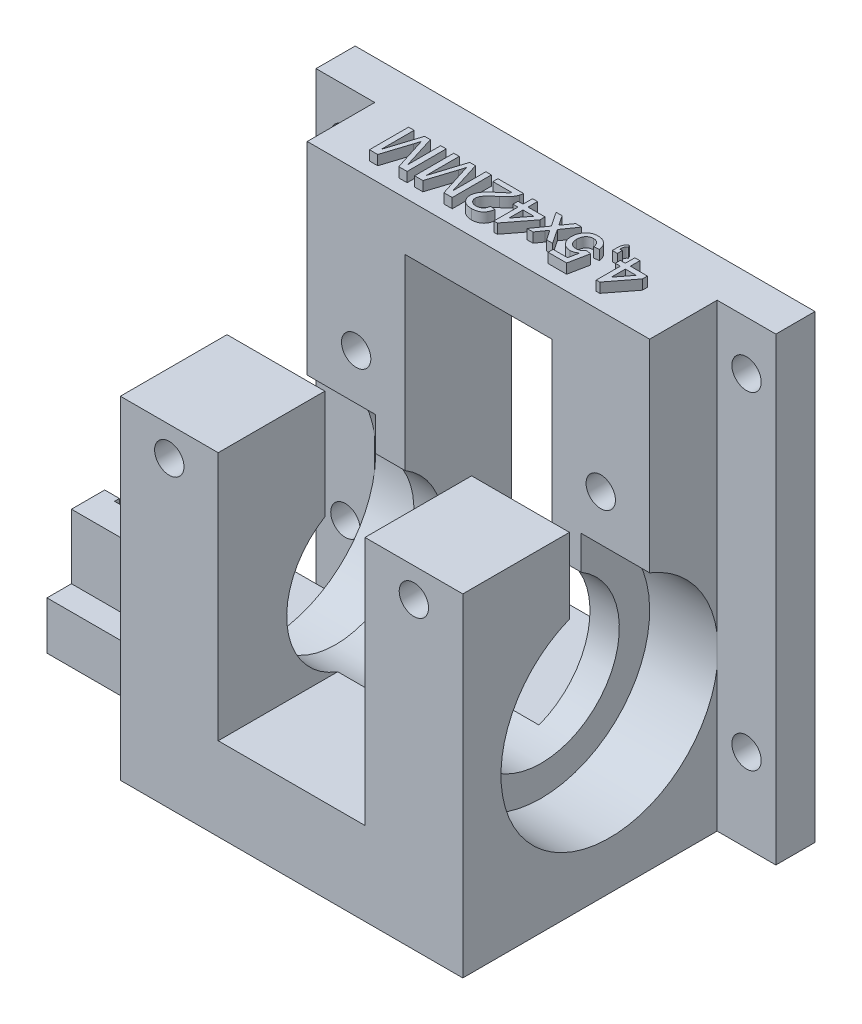
from build123d import *

# Parameters (mm, degrees)
SKETCH_1_W           = 35
SKETCH_1_H           = 30
EXTRUDE_1_DEPTH      = 42
SKETCH_2_W           = 15
SKETCH_2_H           = 30
CUT_EXTRUDE_1_DEPTH  = 33.5
SKETCH_3_R           = 11.1
CUT_EXTRUDE_2_DEPTH  = 7
SKETCH_4_R           = 11.1
CUT_EXTRUDE_3_DEPTH  = 7
SKETCH_5_R           = 8
CUT_EXTRUDE_4_DEPTH  = 29
SKETCH_6_W           = 35
SKETCH_6_H           = 8.2
CUT_EXTRUDE_5_DEPTH  = 20
SKETCH_7_R           = 1.5
CUT_EXTRUDE_6_DEPTH  = 31
SKETCH_9_W           = 15
SKETCH_9_H           = 4.9
EXTRUDE_2_DEPTH      = 15
SKETCH_10_W          = 6
SKETCH_10_H          = 10
EXTRUDE_3_DEPTH      = 6.6
CUT_EXTRUDE_8_DEPTH  = 1.3
SKETCH_12_W          = 3.2
SKETCH_12_H          = 10.2
CUT_EXTRUDE_9_DEPTH  = 1
SKETCH_14_W          = 35
SKETCH_14_H          = 10.9
EXTRUDE_4_DEPTH      = 5
SKETCH_15_W          = 10
SKETCH_15_H          = 10.9
CUT_EXTRUDE_10_DEPTH = 8
EXTRUDE_5_DEPTH      = 1
SKETCH_23_W          = 4
SKETCH_23_H          = 47
EXTRUDE_7_DEPTH      = 6
SKETCH_25_W          = 4
SKETCH_25_H          = 47
EXTRUDE_8_DEPTH      = 6
SKETCH_26_R          = 1.5
CUT_EXTRUDE_12_DEPTH = 31
SKETCH_27_R          = 3
CUT_EXTRUDE_13_DEPTH = 3


with BuildPart() as part:
    # Эскиз1 → Бобышка-Вытянуть1 (new body)
    with BuildSketch(Plane(origin=(0, 0, 0), x_dir=(1, 0, 0), z_dir=(0, 1, 0))):
        Rectangle(SKETCH_1_W, SKETCH_1_H)
    extrude(amount=EXTRUDE_1_DEPTH)

    # Эскиз2 → Вырез-Вытянуть1 (cut)
    with BuildSketch(Plane(origin=(0, 42, 0), x_dir=(1, 0, 0), z_dir=(0, 1, 0))):
        Rectangle(SKETCH_2_W, SKETCH_2_H)
    extrude(amount=-CUT_EXTRUDE_1_DEPTH, mode=Mode.SUBTRACT)

    # Эскиз3 → Вырез-Вытянуть2 (cut)
    with BuildSketch(Plane.ZY.offset(17.5)):
        with Locations((0, 16)):
            Circle(SKETCH_3_R)
    extrude(amount=-CUT_EXTRUDE_2_DEPTH, mode=Mode.SUBTRACT)

    # Эскиз4 → Вырез-Вытянуть3 (cut)
    with BuildSketch(Plane(origin=(17.5, 0, 0), x_dir=(0, 0, -1), z_dir=(1, 0, 0))):
        with Locations(Location((0, 16, 0), (0, 0, 180))):  # turned: the seam where the file's is
            Circle(SKETCH_4_R)
    extrude(amount=-CUT_EXTRUDE_3_DEPTH, mode=Mode.SUBTRACT)

    # Эскиз5 → Вырез-Вытянуть4 (cut, through all)
    with BuildSketch(Plane.ZY.offset(10.5)):
        with Locations((0, 16)):
            Circle(SKETCH_5_R)
    extrude(amount=-CUT_EXTRUDE_4_DEPTH, mode=Mode.SUBTRACT)

    # Эскиз6 → Вырез-Вытянуть5 (cut)
    with BuildSketch(Plane(origin=(0, 42, 0), x_dir=(1, 0, 0), z_dir=(0, 1, 0))):
        Rectangle(SKETCH_6_W, SKETCH_6_H)
    extrude(amount=-CUT_EXTRUDE_5_DEPTH, mode=Mode.SUBTRACT)

    # Эскиз7 → Вырез-Вытянуть6 (cut, through all)
    with BuildSketch(Plane(origin=(0, 0, -15), x_dir=(-1, 0, 0), z_dir=(0, 0, -1))):
        with Locations((-12.5, 31)):
            Circle(SKETCH_7_R)
        with Locations((12.5, 31)):
            Circle(SKETCH_7_R)
    extrude(amount=-CUT_EXTRUDE_6_DEPTH, mode=Mode.SUBTRACT)

    # Эскиз9 → Бобышка-Вытянуть2 (add)
    with BuildSketch(Plane(origin=(-17.5, 0, 0), x_dir=(0, 0, -1), z_dir=(1, 0, 0))):
        with Locations((0, 2.45)):
            Rectangle(SKETCH_9_W, SKETCH_9_H)
    extrude(amount=-EXTRUDE_2_DEPTH)

    # Эскиз10 → Бобышка-Вытянуть3 (add)
    with BuildSketch(Plane(origin=(0, 4.9, 0), x_dir=(1, 0, 0), z_dir=(0, 1, 0))):
        with Locations((-29.5, 0)):
            Rectangle(SKETCH_10_W, SKETCH_10_H)
    extrude(amount=EXTRUDE_3_DEPTH)

    # Эскиз11 → Вырез-Вытянуть8 (cut)
    with BuildSketch(Plane(origin=(0, 11.5, 0), x_dir=(1, 0, 0), z_dir=(0, 1, 0))):
        Polygon((-31, 1.6), (-32.5, 1.6), (-32.5, -1.6), (-31, -1.6), (-31, -2.1), (-28, -2.1), (-28, 2.1), (-31, 2.1), align=None)
    extrude(amount=-CUT_EXTRUDE_8_DEPTH, mode=Mode.SUBTRACT)

    # Эскиз12 → Вырез-Вытянуть9 (cut)
    with BuildSketch(Plane.ZY.offset(32.5)):
        with Locations((0, 5.1)):
            Rectangle(SKETCH_12_W, SKETCH_12_H)
    extrude(amount=-CUT_EXTRUDE_9_DEPTH, mode=Mode.SUBTRACT)

    # Эскиз14 → Бобышка-Вытянуть4 (add)
    with BuildSketch(Plane(origin=(0, 42, 0), x_dir=(1, 0, 0), z_dir=(0, 1, 0))):
        with Locations((0, 9.55)):
            Rectangle(SKETCH_14_W, SKETCH_14_H)
    extrude(amount=EXTRUDE_4_DEPTH)

    # Эскиз15 → Вырез-Вытянуть10 (cut)
    with BuildSketch(Plane(origin=(0, 42, 0), x_dir=(1, 0, 0), z_dir=(0, 1, 0))):
        with Locations((-12.5, -9.55)):
            Rectangle(SKETCH_15_W, SKETCH_15_H)
        with Locations((12.5, -9.55)):
            Rectangle(SKETCH_15_W, SKETCH_15_H)
    extrude(amount=-CUT_EXTRUDE_10_DEPTH, mode=Mode.SUBTRACT)

    # Эскиз17 → Бобышка-Вытянуть5 (add)
    with BuildSketch(Plane(origin=(0, 47, 0), x_dir=(1, 0, 0), z_dir=(0, 1, 0))):
        Polygon((11.051282051, 9.55), (11.051282051, 8.575641026), (12.794871795, 8.575641026), (12.794871795, 8.062820513), (10.897435897, 5.601282051), (10.538461538, 5.601282051), (10.538461538, 8.062820513), (10.025641026, 8.062820513), (10.025641026, 8.575641026), (10.538461538, 8.575641026), (10.538461538, 9.55), align=None)
        Polygon((11.051282051, 8.062820513), (11.051282051, 6.622115385), (12.161858974, 8.062820513), align=None, mode=Mode.SUBTRACT)
        with BuildLine():
            Line((9.256410256, 9.55), (9.256410256, 9.037179487))
            Line((9.256410256, 9.037179487), (8.743589744, 9.037179487))
            Line((8.743589744, 9.037179487), (8.743589744, 9.55))
            add(Edge.make_bspline(
                [(8.743589744, 9.55), (8.744762203, 9.60080674), (8.746998436, 9.697710464), (8.765236115, 9.835295888), (8.795282204, 9.957567435), (8.837586451, 10.066022105), (8.895741676, 10.16039483), (8.967235433, 10.243648121), (9.053922116, 10.314994822), (9.120081135, 10.351752907), (9.153846154, 10.370512821)],
                knots=[0, 0, 0, 0, 1.252840278, 2.389542986, 3.415356866, 4.352460491, 5.24846073, 6.135967884, 7.048669687, 8, 8, 8, 8], degree=3))
            Line((9.153846154, 10.370512821), (9.256410256, 10.165384615))
            add(Edge.make_bspline(
                [(9.256410256, 10.165384615), (9.236136991, 10.15270943), (9.195793548, 10.127486034), (9.144116682, 10.077328516), (9.100530598, 10.019236479), (9.065074864, 9.951439544), (9.038948006, 9.871529248), (9.019447544, 9.777755567), (9.005956084, 9.668947552), (9.003109603, 9.591175547), (9.001602564, 9.55)],
                knots=[0, 0, 0, 0, 0.818684612, 1.629167986, 2.454191951, 3.302962822, 4.242204463, 5.329983798, 6.586388792, 8, 8, 8, 8], degree=3))
            Line((9.001602564, 9.55), (9.256410256, 9.55))
        make_face()
        with BuildLine():
            Line((7.974358974, 8.473076923), (7.461538462, 8.421794872))
            add(Edge.make_bspline(
                [(7.461538462, 8.421794872), (7.456460733, 8.450689493), (7.446583762, 8.506894026), (7.427762102, 8.588251754), (7.403318124, 8.663835357), (7.375852623, 8.734299433), (7.343205242, 8.798898912), (7.307831533, 8.858653786), (7.266115474, 8.911442943), (7.222256638, 8.960027307), (7.174118215, 9.002838723), (7.121235704, 9.038930225), (7.065084563, 9.070417874), (7.004980891, 9.096198562), (6.940832572, 9.115068668), (6.873456044, 9.129991683), (6.801983712, 9.137511319), (6.753218627, 9.138989984), (6.728365385, 9.13974359)],
                knots=[0, 0, 0, 0, 1.237781394, 2.407677316, 3.51963579, 4.58689595, 5.594855907, 6.570874, 7.510833816, 8.428091223, 9.330271693, 10.221190844, 11.124215526, 12.043132878, 12.973586933, 13.941700858, 14.950982896, 16, 16, 16, 16], degree=3))
            add(Edge.make_bspline(
                [(6.728365385, 9.13974359), (6.697879298, 9.138998436), (6.638262427, 9.137541256), (6.551476168, 9.125474441), (6.469793796, 9.104984114), (6.392440011, 9.078387527), (6.320650702, 9.041973623), (6.254638587, 8.99701751), (6.192074052, 8.946020266), (6.136594245, 8.885375865), (6.086108178, 8.81931477), (6.042530672, 8.747217103), (6.005845696, 8.670082001), (5.974960646, 8.587927748), (5.952154369, 8.500284059), (5.935378488, 8.40761745), (5.924609047, 8.309868818), (5.923594873, 8.242870598), (5.923076923, 8.208653846)],
                knots=[0, 0, 0, 0, 1.052750423, 2.05869932, 3.018624241, 3.958205853, 4.878289862, 5.789216265, 6.712947111, 7.659433357, 8.620775926, 9.5811884, 10.56329027, 11.567503128, 12.60809625, 13.686605721, 14.818523251, 16, 16, 16, 16], degree=3))
            add(Edge.make_bspline(
                [(5.923076923, 8.208653846), (5.923665617, 8.176045727), (5.92481194, 8.112550156), (5.934465851, 8.020090048), (5.950753135, 7.933149565), (5.971827355, 7.850770472), (6.00087551, 7.774240043), (6.035328257, 7.702448663), (6.077534321, 7.636919954), (6.124491351, 7.575613592), (6.178122208, 7.520654908), (6.239151436, 7.47424926), (6.305184894, 7.433634947), (6.377552563, 7.400699273), (6.456297057, 7.376229304), (6.540635873, 7.357401866), (6.631444151, 7.347499404), (6.69388974, 7.3457634), (6.725961538, 7.344871795)],
                knots=[0, 0, 0, 0, 1.165854935, 2.270189951, 3.319242023, 4.32700288, 5.306253956, 6.24172124, 7.169108591, 8.088047231, 8.999810445, 9.905349262, 10.822648491, 11.767237767, 12.739852311, 13.766490849, 14.852878837, 16, 16, 16, 16], degree=3))
            add(Edge.make_bspline(
                [(6.725961538, 7.344871795), (6.765831836, 7.346075377), (6.842557476, 7.348391528), (6.952581265, 7.366774493), (7.052239813, 7.397884441), (7.141490161, 7.441871146), (7.221133837, 7.496136836), (7.292349446, 7.558219874), (7.357127652, 7.626487707), (7.39247764, 7.677959269), (7.41025641, 7.703846154)],
                knots=[0, 0, 0, 0, 1.182595606, 2.275764447, 3.298426239, 4.269611407, 5.217028086, 6.149744883, 7.069440711, 8, 8, 8, 8], degree=3))
            Line((7.41025641, 7.703846154), (7.923076923, 7.652564103))
            Line((7.923076923, 7.652564103), (7.512820513, 5.601282051))
            Line((7.512820513, 5.601282051), (5.615384615, 5.601282051))
            Line((5.615384615, 5.601282051), (5.615384615, 6.114102564))
            Line((5.615384615, 6.114102564), (7.09375, 6.114102564))
            Line((7.09375, 6.114102564), (7.297275641, 7.150160256))
            add(Edge.make_bspline(
                [(7.297275641, 7.150160256), (7.268978306, 7.128929634), (7.213406817, 7.087236051), (7.126747153, 7.032591296), (7.038983143, 6.986841178), (6.950576337, 6.948546155), (6.860301127, 6.919728313), (6.769141059, 6.899121223), (6.676964847, 6.88537448), (6.615166257, 6.884015656), (6.584134615, 6.883333333)],
                knots=[0, 0, 0, 0, 1.093799738, 2.148049664, 3.164132611, 4.152263193, 5.124065093, 6.089950765, 7.040884846, 8, 8, 8, 8], degree=3))
            add(Edge.make_bspline(
                [(6.584134615, 6.883333333), (6.543748064, 6.884391846), (6.464217151, 6.886476314), (6.347021786, 6.903592241), (6.234978069, 6.932674585), (6.127137436, 6.971751814), (6.025308421, 7.023832328), (5.927334208, 7.085605854), (5.835155558, 7.16005899), (5.748365663, 7.244413035), (5.669029336, 7.337778469), (5.600276379, 7.439053291), (5.541050547, 7.546436856), (5.493068907, 7.660316925), (5.456004725, 7.780892463), (5.429974508, 7.907543666), (5.413427229, 8.040751555), (5.411329647, 8.131680793), (5.41025641, 8.178205128)],
                knots=[0, 0, 0, 0, 0.991915953, 1.953323076, 2.9018799, 3.831962974, 4.765165785, 5.70629427, 6.67268229, 7.670376632, 8.67608782, 9.677121355, 10.672677061, 11.684236821, 12.707498642, 13.766656378, 14.857300131, 16, 16, 16, 16], degree=3))
            add(Edge.make_bspline(
                [(5.41025641, 8.178205128), (5.411156001, 8.222583072), (5.412932951, 8.310242175), (5.427752663, 8.439380631), (5.451534872, 8.564053302), (5.485561261, 8.683683722), (5.527786942, 8.799330016), (5.581285743, 8.909565964), (5.642451314, 9.016580163), (5.691606696, 9.082518807), (5.716346154, 9.115705128)],
                knots=[0, 0, 0, 0, 1.059762356, 2.093333049, 3.100576568, 4.08823236, 5.061210495, 6.037154334, 7.012117566, 8, 8, 8, 8], degree=3))
            add(Edge.make_bspline(
                [(5.716346154, 9.115705128), (5.747771179, 9.154439921), (5.809587576, 9.230635417), (5.916555204, 9.329653668), (6.031909427, 9.413416188), (6.154974873, 9.483107829), (6.287290682, 9.536524881), (6.428159547, 9.573425407), (6.577145806, 9.597839493), (6.679387351, 9.600118743), (6.731570513, 9.601282051)],
                knots=[0, 0, 0, 0, 1.023063757, 2.01247625, 2.982117532, 3.944599247, 4.908953799, 5.902627458, 6.929519989, 8, 8, 8, 8], degree=3))
            add(Edge.make_bspline(
                [(6.731570513, 9.601282051), (6.774615114, 9.600406486), (6.858818996, 9.598693703), (6.98212694, 9.583877782), (7.099337418, 9.560077146), (7.210909624, 9.526516179), (7.315783802, 9.48202305), (7.415429606, 9.429357654), (7.507610872, 9.365184154), (7.594184528, 9.293303776), (7.67336044, 9.213562045), (7.743516838, 9.126412248), (7.804411227, 9.03273972), (7.858083566, 8.933562687), (7.899810221, 8.826848145), (7.934761175, 8.714806315), (7.960674347, 8.596312118), (7.969749603, 8.514586039), (7.974358974, 8.473076923)],
                knots=[0, 0, 0, 0, 1.109091339, 2.169605288, 3.195665858, 4.188679546, 5.166738875, 6.127665597, 7.0881237, 8.055905583, 9.024592931, 9.979285586, 10.933953421, 11.900951517, 12.880148814, 13.881763063, 14.92413606, 16, 16, 16, 16], degree=3))
        make_face()
        with BuildLine():
            Line((5.102564103, 9.55), (4.076923077, 8.088461538))
            Line((4.076923077, 8.088461538), (5.051282051, 6.626923077))
            Line((5.051282051, 6.626923077), (4.436698718, 6.626923077))
            Line((4.436698718, 6.626923077), (3.963141026, 7.336057692))
            add(Edge.make_bspline(
                [(3.963141026, 7.336057692), (3.943145685, 7.366263796), (3.905403959, 7.423278603), (3.851487363, 7.503520103), (3.804239172, 7.574051249), (3.774842718, 7.617843871), (3.761217949, 7.638141026)],
                knots=[0, 0, 0, 0, 1.196329119, 2.258102392, 3.192659312, 4, 4, 4, 4], degree=3))
            add(Edge.make_bspline(
                [(3.761217949, 7.638141026), (3.728351968, 7.591408991), (3.662834044, 7.498249262), (3.597476074, 7.404977245), (3.564903846, 7.35849359)],
                knots=[0, 0, 0, 0, 1.003266858, 2, 2, 2, 2], degree=3))
            Line((3.564903846, 7.35849359), (3.051282051, 6.626923077))
            Line((3.051282051, 6.626923077), (2.4375, 6.626923077))
            Line((2.4375, 6.626923077), (3.462339744, 8.087660256))
            Line((3.462339744, 8.087660256), (2.487179487, 9.55))
            Line((2.487179487, 9.55), (3.101762821, 9.55))
            Line((3.101762821, 9.55), (3.670673077, 8.696634615))
            Line((3.670673077, 8.696634615), (3.778044872, 8.537980769))
            Line((3.778044872, 8.537980769), (4.487980769, 9.55))
            Line((4.487980769, 9.55), (5.102564103, 9.55))
        make_face()
        Polygon((0.58974359, 9.55), (0.58974359, 8.575641026), (2.333333333, 8.575641026), (2.333333333, 8.062820513), (0.435897436, 5.601282051), (0.076923077, 5.601282051), (0.076923077, 8.062820513), (-0.435897436, 8.062820513), (-0.435897436, 8.575641026), (0.076923077, 8.575641026), (0.076923077, 9.55), align=None)
        Polygon((0.58974359, 8.062820513), (0.58974359, 6.622115385), (1.700320513, 8.062820513), align=None, mode=Mode.SUBTRACT)
        with BuildLine():
            Line((-3.461538462, 9.037179487), (-3.461538462, 9.55))
            Line((-3.461538462, 9.55), (-0.846153846, 9.55))
            add(Edge.make_bspline(
                [(-0.846153846, 9.55), (-0.846082735, 9.519519453), (-0.845941371, 9.458926348), (-0.856451896, 9.368959417), (-0.872291123, 9.280102742), (-0.890639052, 9.222910301), (-0.899839744, 9.194230769)],
                knots=[0, 0, 0, 0, 1.010600758, 2.009000657, 3.001600101, 4, 4, 4, 4], degree=3))
            add(Edge.make_bspline(
                [(-0.899839744, 9.194230769), (-0.916779692, 9.147353172), (-0.951190909, 9.052127668), (-1.021694058, 8.914539873), (-1.104395846, 8.777782713), (-1.18460512, 8.665929608), (-1.25815358, 8.577261327), (-1.318832327, 8.507068152), (-1.387177214, 8.4361128), (-1.461952315, 8.36313594), (-1.542700917, 8.288131646), (-1.629420726, 8.210750893), (-1.723168438, 8.13246432), (-1.7886128, 8.080571583), (-1.822115385, 8.05400641)],
                knots=[0, 0, 0, 0, 1.204775845, 2.447339333, 3.731688634, 5.069474332, 5.771881205, 6.518320379, 7.313534551, 8.154278236, 9.045805008, 9.979490009, 10.965651065, 12, 12, 12, 12], degree=3))
            add(Edge.make_bspline(
                [(-1.822115385, 8.05400641), (-1.873583803, 8.010686271), (-1.972689508, 7.927270595), (-2.112642371, 7.803489508), (-2.240466257, 7.688551596), (-2.354126908, 7.580443046), (-2.454550075, 7.480210154), (-2.541983882, 7.388087306), (-2.617141923, 7.304339128), (-2.679226482, 7.226005854), (-2.731197355, 7.152053321), (-2.776319435, 7.080316644), (-2.812541985, 7.008283907), (-2.843626375, 6.937323066), (-2.867741932, 6.867153892), (-2.884713823, 6.797147878), (-2.895681037, 6.727967714), (-2.896857451, 6.681716305), (-2.897435897, 6.658974359)],
                knots=[0, 0, 0, 0, 1.782511555, 3.432339066, 4.950556168, 6.337242158, 7.588364383, 8.709771971, 9.70247892, 10.569050646, 11.3564271, 12.096888545, 12.812232926, 13.490631961, 14.148641375, 14.7751826, 15.397753892, 16, 16, 16, 16], degree=3))
            add(Edge.make_bspline(
                [(-2.897435897, 6.658974359), (-2.896879163, 6.636494046), (-2.89578688, 6.592388895), (-2.885421202, 6.527842176), (-2.87099607, 6.465678688), (-2.847656894, 6.40703374), (-2.819938503, 6.350109704), (-2.784024488, 6.296761456), (-2.743372767, 6.244972349), (-2.695881727, 6.197454776), (-2.64437183, 6.152921146), (-2.587038785, 6.115707339), (-2.52657792, 6.083233275), (-2.462464322, 6.05676427), (-2.39421562, 6.036629538), (-2.32231158, 6.022524983), (-2.246489973, 6.01342694), (-2.194738127, 6.012177498), (-2.168269231, 6.011538462)],
                knots=[0, 0, 0, 0, 0.987999173, 1.938400644, 2.870175051, 3.788745887, 4.708217872, 5.649938364, 6.61138593, 7.600013579, 8.600369295, 9.600725011, 10.599354487, 11.616065131, 12.645726306, 13.724038792, 14.835941382, 16, 16, 16, 16], degree=3))
            add(Edge.make_bspline(
                [(-2.168269231, 6.011538462), (-2.140465958, 6.012178615), (-2.086052911, 6.013431441), (-2.006502895, 6.022505424), (-1.931031689, 6.036484496), (-1.859837716, 6.057377903), (-1.79343005, 6.085090247), (-1.730298763, 6.116672913), (-1.672120047, 6.155686717), (-1.61882603, 6.200662994), (-1.569496464, 6.249756283), (-1.527853004, 6.305255231), (-1.491169963, 6.364389666), (-1.462860375, 6.429200021), (-1.439189909, 6.497660549), (-1.422317066, 6.570946029), (-1.413059075, 6.648857951), (-1.411204191, 6.702220684), (-1.41025641, 6.729487179)],
                knots=[0, 0, 0, 0, 1.131007971, 2.213465715, 3.25352735, 4.250693176, 5.225400803, 6.177988609, 7.118348849, 8.067272485, 9.012455277, 9.942714685, 10.883890855, 11.837222194, 12.81320114, 13.828092093, 14.890230783, 16, 16, 16, 16], degree=3))
            Line((-1.41025641, 6.729487179), (-0.897435897, 6.678205128))
            add(Edge.make_bspline(
                [(-0.897435897, 6.678205128), (-0.902682148, 6.633511111), (-0.912888276, 6.546562747), (-0.938322126, 6.420640269), (-0.973985758, 6.303468047), (-1.016806537, 6.193542674), (-1.070028073, 6.092144418), (-1.132080914, 5.998963916), (-1.201772535, 5.912932004), (-1.281651179, 5.837210809), (-1.36861221, 5.769133514), (-1.463516346, 5.710944199), (-1.565313196, 5.660697713), (-1.674316407, 5.620003899), (-1.7905577, 5.588840701), (-1.913835182, 5.566554173), (-2.044294277, 5.552801079), (-2.133779886, 5.550947015), (-2.179487179, 5.55)],
                knots=[0, 0, 0, 0, 1.130828508, 2.199929528, 3.223633236, 4.205997909, 5.160910297, 6.095620583, 7.016241394, 7.937376102, 8.855913919, 9.787436367, 10.73018861, 11.705300542, 12.706861604, 13.751074331, 14.851297925, 16, 16, 16, 16], degree=3))
            add(Edge.make_bspline(
                [(-2.179487179, 5.55), (-2.225741232, 5.550792323), (-2.315844398, 5.552335771), (-2.447141617, 5.568119175), (-2.571015121, 5.592720915), (-2.687960685, 5.626942232), (-2.797357101, 5.672137793), (-2.899578502, 5.726571863), (-2.99430275, 5.791179471), (-3.080238246, 5.865680577), (-3.157750046, 5.947040368), (-3.225520375, 6.033937345), (-3.28283039, 6.125747007), (-3.329330768, 6.222266479), (-3.366034453, 6.323411438), (-3.390931794, 6.42940932), (-3.408133355, 6.54009289), (-3.409539317, 6.615636557), (-3.41025641, 6.654166667)],
                knots=[0, 0, 0, 0, 1.195184963, 2.328227347, 3.412838735, 4.457075639, 5.472567195, 6.467212925, 7.445817268, 8.429862391, 9.40172103, 10.346392722, 11.273671097, 12.19390528, 13.111181922, 14.048965502, 15.00489906, 16, 16, 16, 16], degree=3))
            add(Edge.make_bspline(
                [(-3.41025641, 6.654166667), (-3.409177564, 6.693755674), (-3.40701749, 6.773021054), (-3.389440224, 6.89133178), (-3.361425519, 7.008540721), (-3.321690521, 7.125725416), (-3.26782673, 7.243512483), (-3.200346554, 7.364055347), (-3.116792857, 7.486526692), (-3.036708456, 7.590771671), (-2.962057858, 7.678045626), (-2.895335383, 7.750039796), (-2.819088482, 7.827693393), (-2.733561398, 7.910748414), (-2.638345813, 7.999021549), (-2.534675981, 8.093615681), (-2.42060373, 8.192635602), (-2.341395174, 8.260261046), (-2.300480769, 8.295192308)],
                knots=[0, 0, 0, 0, 0.92705835, 1.85616256, 2.795554264, 3.747284035, 4.749796966, 5.825476635, 6.979499781, 8.219726678, 8.903135141, 9.669166345, 10.518679137, 11.452302006, 12.461664484, 13.560176038, 14.739732795, 16, 16, 16, 16], degree=3))
            add(Edge.make_bspline(
                [(-2.300480769, 8.295192308), (-2.265376068, 8.323632107), (-2.198303809, 8.377970175), (-2.104154471, 8.457891049), (-2.018131649, 8.529130419), (-1.941408883, 8.592833141), (-1.874405456, 8.649747699), (-1.818010926, 8.700563375), (-1.76963496, 8.742669999), (-1.697323119, 8.808927046), (-1.605337729, 8.902681191), (-1.537302368, 8.993705132), (-1.504807692, 9.037179487)],
                knots=[0, 0, 0, 0, 1.242120814, 2.373239094, 3.395283395, 4.312960318, 5.115054069, 5.812109485, 6.400004863, 6.878180934, 8.508973911, 10, 10, 10, 10], degree=3))
            Line((-1.504807692, 9.037179487), (-3.461538462, 9.037179487))
        make_face()
        with BuildLine():
            Line((-4.128205128, 9.55), (-4.128205128, 5.55))
            Line((-4.128205128, 5.55), (-4.976762821, 5.55))
            Line((-4.976762821, 5.55), (-5.87099359, 8.356891026))
            add(Edge.make_bspline(
                [(-5.87099359, 8.356891026), (-5.880834637, 8.388688209), (-5.899866651, 8.450182111), (-5.928088868, 8.538984965), (-5.953766355, 8.621507311), (-5.976892975, 8.698011825), (-5.998717865, 8.768118663), (-6.017614781, 8.832403106), (-6.035680848, 8.890150808), (-6.04626837, 8.926851361), (-6.051282051, 8.944230769)],
                knots=[0, 0, 0, 0, 1.300204174, 2.514519184, 3.639827924, 4.676153899, 5.636536826, 6.507959918, 7.293450077, 8, 8, 8, 8], degree=3))
            add(Edge.make_bspline(
                [(-6.051282051, 8.944230769), (-6.056866128, 8.925259626), (-6.068749399, 8.88488782), (-6.088014083, 8.821410075), (-6.108512254, 8.751164808), (-6.133042282, 8.675359419), (-6.158611933, 8.592804761), (-6.185450609, 8.503569392), (-6.2164085, 8.408544221), (-6.236981565, 8.342756834), (-6.247596154, 8.308814103)],
                knots=[0, 0, 0, 0, 0.713638162, 1.518667645, 2.393860736, 3.354087503, 4.393659122, 5.512594909, 6.716633584, 8, 8, 8, 8], degree=3))
            Line((-6.247596154, 8.308814103), (-7.133012821, 5.55))
            Line((-7.133012821, 5.55), (-7.974358974, 5.55))
            Line((-7.974358974, 5.55), (-7.974358974, 9.55))
            Line((-7.974358974, 9.55), (-7.41025641, 9.55))
            Line((-7.41025641, 9.55), (-7.41025641, 6.165384615))
            Line((-7.41025641, 6.165384615), (-6.342948718, 9.55))
            Line((-6.342948718, 9.55), (-5.753205128, 9.55))
            Line((-5.753205128, 9.55), (-4.692307692, 6.165384615))
            Line((-4.692307692, 6.165384615), (-4.692307692, 9.55))
            Line((-4.692307692, 9.55), (-4.128205128, 9.55))
        make_face()
        with BuildLine():
            Line((-8.743589744, 9.55), (-8.743589744, 5.55))
            Line((-8.743589744, 5.55), (-9.592147436, 5.55))
            Line((-9.592147436, 5.55), (-10.486378205, 8.356891026))
            add(Edge.make_bspline(
                [(-10.486378205, 8.356891026), (-10.496219253, 8.388688209), (-10.515251266, 8.450182111), (-10.543473484, 8.538984965), (-10.56915097, 8.621507311), (-10.592277591, 8.698011825), (-10.614102481, 8.768118663), (-10.632999397, 8.832403106), (-10.651065463, 8.890150808), (-10.661652986, 8.926851361), (-10.666666667, 8.944230769)],
                knots=[0, 0, 0, 0, 1.300204174, 2.514519184, 3.639827924, 4.676153899, 5.636536826, 6.507959918, 7.293450077, 8, 8, 8, 8], degree=3))
            add(Edge.make_bspline(
                [(-10.666666667, 8.944230769), (-10.672250743, 8.925259626), (-10.684134015, 8.88488782), (-10.703398698, 8.821410075), (-10.723896869, 8.751164808), (-10.748426897, 8.675359419), (-10.773996548, 8.592804761), (-10.800835225, 8.503569392), (-10.831793115, 8.408544221), (-10.852366181, 8.342756834), (-10.862980769, 8.308814103)],
                knots=[0, 0, 0, 0, 0.713638162, 1.518667645, 2.393860736, 3.354087503, 4.393659122, 5.512594909, 6.716633584, 8, 8, 8, 8], degree=3))
            Line((-10.862980769, 8.308814103), (-11.748397436, 5.55))
            Line((-11.748397436, 5.55), (-12.58974359, 5.55))
            Line((-12.58974359, 5.55), (-12.58974359, 9.55))
            Line((-12.58974359, 9.55), (-12.025641026, 9.55))
            Line((-12.025641026, 9.55), (-12.025641026, 6.165384615))
            Line((-12.025641026, 6.165384615), (-10.958333333, 9.55))
            Line((-10.958333333, 9.55), (-10.368589744, 9.55))
            Line((-10.368589744, 9.55), (-9.307692308, 6.165384615))
            Line((-9.307692308, 6.165384615), (-9.307692308, 9.55))
            Line((-9.307692308, 9.55), (-8.743589744, 9.55))
        make_face()
    extrude(amount=EXTRUDE_5_DEPTH)

    # Эскиз23 → Бобышка-Вытянуть7 (add)
    with BuildSketch(Plane(origin=(17.5, 0, 0), x_dir=(0, 0, -1), z_dir=(1, 0, 0))):
        with Locations((13, 23.5)):
            Rectangle(SKETCH_23_W, SKETCH_23_H)
    extrude(amount=EXTRUDE_7_DEPTH)

    # Эскиз25 → Бобышка-Вытянуть8 (add)
    with BuildSketch(Plane.ZY.offset(17.5)):
        with Locations((-13, 23.5)):
            Rectangle(SKETCH_25_W, SKETCH_25_H)
    extrude(amount=EXTRUDE_8_DEPTH)

    # Эскиз26 → Вырез-Вытянуть12 (cut, through all)
    with BuildSketch(Plane(origin=(0, 0, -15), x_dir=(-1, 0, 0), z_dir=(0, 0, -1))):
        with Locations((-20.5, 42)):
            Circle(SKETCH_26_R)
        with Locations((-20.5, 8.5)):
            Circle(SKETCH_26_R)
        with Locations((20.5, 42)):
            Circle(SKETCH_26_R)
        with Locations((20.5, 8.5)):
            Circle(SKETCH_26_R)
    extrude(amount=-CUT_EXTRUDE_12_DEPTH, mode=Mode.SUBTRACT)

    # Эскиз27 → Вырез-Вытянуть13 (cut)
    with BuildSketch(Plane(origin=(0, 0, -15), x_dir=(-1, 0, 0), z_dir=(0, 0, -1))):
        with Locations((12.5, 31)):
            Circle(SKETCH_27_R)
        with Locations((-12.5, 31)):
            Circle(SKETCH_27_R)
    extrude(amount=-CUT_EXTRUDE_13_DEPTH, mode=Mode.SUBTRACT)


solid = part.part
